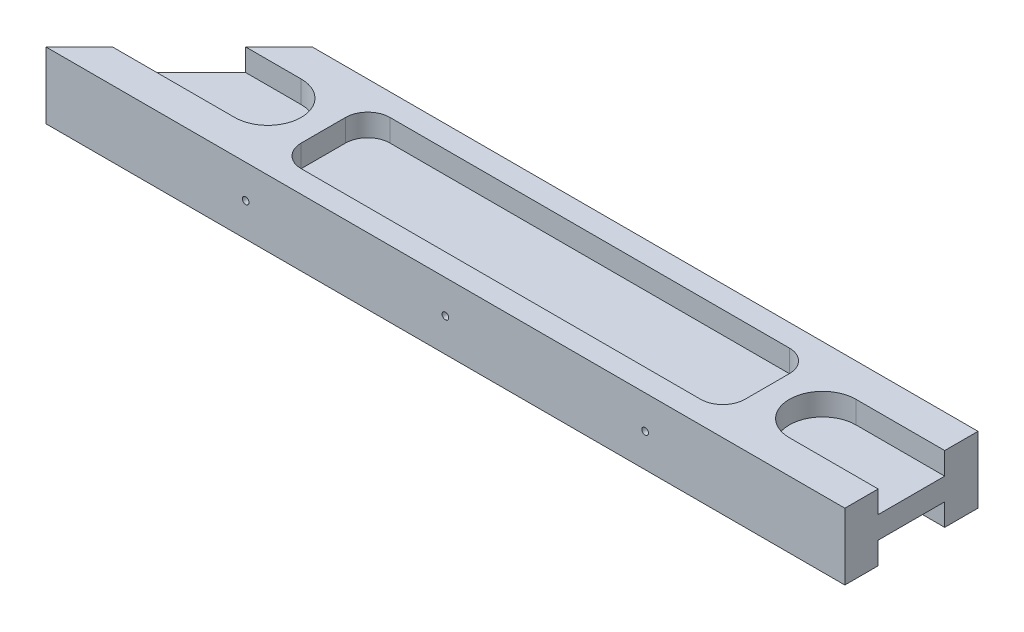
from build123d import *

# Parameters (mm, degrees)
BOSS_EXTRUDE1_DEPTH = 15
CUT_EXTRUDE1_DEPTH  = 5
CUT_EXTRUDE2_DEPTH  = 5
SKETCH4_R           = 0.75
CUT_EXTRUDE3_DEPTH  = 30
CUT_EXTRUDE4_DEPTH  = 5


with BuildPart() as part:
    # Sketch1 → Boss-Extrude1 (new body)
    with BuildSketch(Plane(origin=(0, 0, 0), x_dir=(1, 0, 0), z_dir=(0, 1, 0))):
        Polygon((0, 0), (180, 0), (180, 30), (30, 30), align=None)
    extrude(amount=BOSS_EXTRUDE1_DEPTH)

    # Sketch2 → Cut-Extrude1 (cut)
    with BuildSketch(Plane(origin=(0, 15, 0), x_dir=(1, 0, 0), z_dir=(0, 1, 0))):
        with BuildLine():
            Line((-5, 22.5), (35, 22.5))
            ThreePointArc((35, 22.5), (42.5, 15), (35, 7.5))
            Line((35, 7.5), (-5, 7.5))
            ThreePointArc((-5, 7.5), (-12.5, 15), (-5, 22.5))
        make_face()
        with BuildLine():
            Line((200, 22.5), (160, 22.5))
            ThreePointArc((160, 22.5), (152.5, 15), (160, 7.5))
            Line((160, 7.5), (200, 7.5))
            ThreePointArc((200, 7.5), (207.5, 15), (200, 22.5))
        make_face()
    extrude(amount=-CUT_EXTRUDE1_DEPTH, mode=Mode.SUBTRACT)

    # Sketch3 → Cut-Extrude2 (cut)
    with BuildSketch(Plane.XZ):
        with BuildLine():
            Line((22.5, -22.5), (7.5, -7.5))
            Line((7.5, -7.5), (35, -7.5))
            ThreePointArc((35, -7.5), (42.5, -15), (35, -22.5))
            Line((35, -22.5), (22.5, -22.5))
        make_face()
        with BuildLine():
            Line((180, -7.5), (180, -22.5))
            Line((180, -22.5), (160, -22.5))
            ThreePointArc((160, -22.5), (152.5, -15), (160, -7.5))
            Line((160, -7.5), (180, -7.5))
        make_face()
    extrude(amount=-CUT_EXTRUDE2_DEPTH, mode=Mode.SUBTRACT)

    # Sketch4 → Cut-Extrude3 (cut)
    with BuildSketch(Plane.XY):
        with Locations((90, 7.5)):
            Circle(SKETCH4_R)
        with Locations((45, 7.5)):
            Circle(SKETCH4_R)
        with Locations((135, 7.5)):
            Circle(SKETCH4_R)
    extrude(amount=-CUT_EXTRUDE3_DEPTH, mode=Mode.SUBTRACT)

    # Sketch5 → Cut-Extrude4 (cut)
    with BuildSketch(Plane(origin=(0, 15, 0), x_dir=(1, 0, 0), z_dir=(0, 1, 0))):
        with BuildLine():
            Line((52.5, 25), (142.5, 25))
            ThreePointArc((142.5, 25), (146.035533906, 23.535533906), (147.5, 20))
            Line((147.5, 20), (147.5, 10))
            ThreePointArc((147.5, 10), (146.035533906, 6.464466094), (142.5, 5))
            Line((142.5, 5), (52.5, 5))
            ThreePointArc((52.5, 5), (48.964466094, 6.464466094), (47.5, 10))
            Line((47.5, 10), (47.5, 20))
            ThreePointArc((47.5, 20), (48.964466094, 23.535533906), (52.5, 25))
        make_face()
    extrude(amount=-CUT_EXTRUDE4_DEPTH, mode=Mode.SUBTRACT)


solid = part.part
